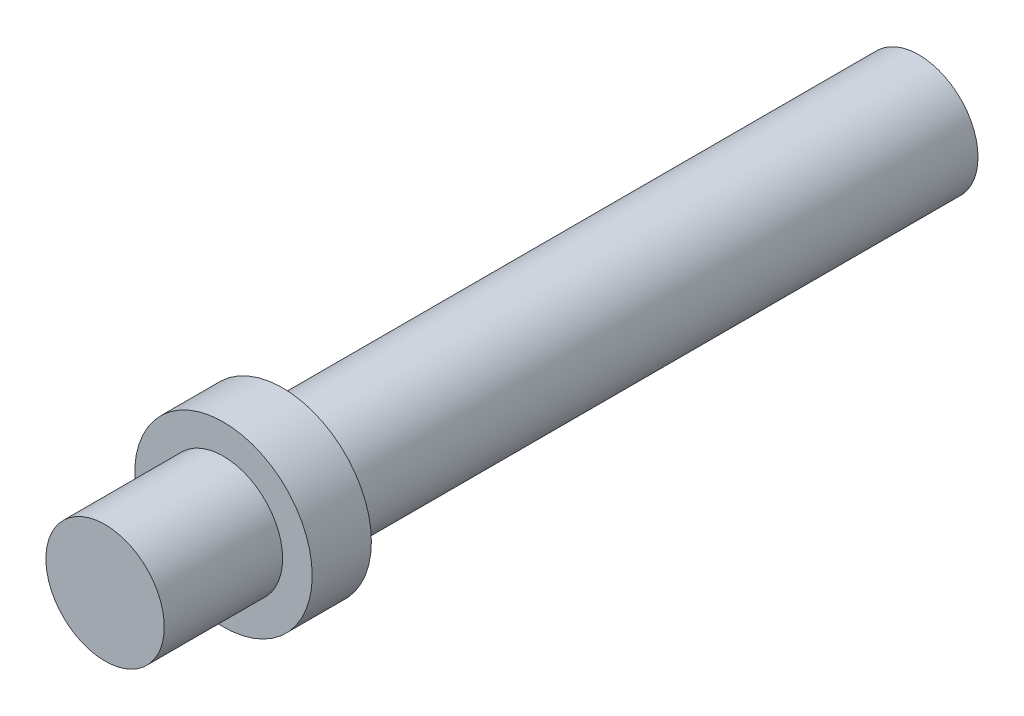
from build123d import *


with BuildPart() as part:
    # Croquis1 → Revolución1 (revolve)
    with BuildSketch(Plane(origin=(0, 0, 0), x_dir=(0, 0, -1), z_dir=(1, 0, 0))):
        Polygon((0, 0), (27.5, 0), (27.5, 2), (6, 2), (6, 3), (4, 3), (4, 2), (0, 2), align=None)
    revolve(axis=Axis((0, 0, 0), (0, 0, -1)))


solid = part.part
